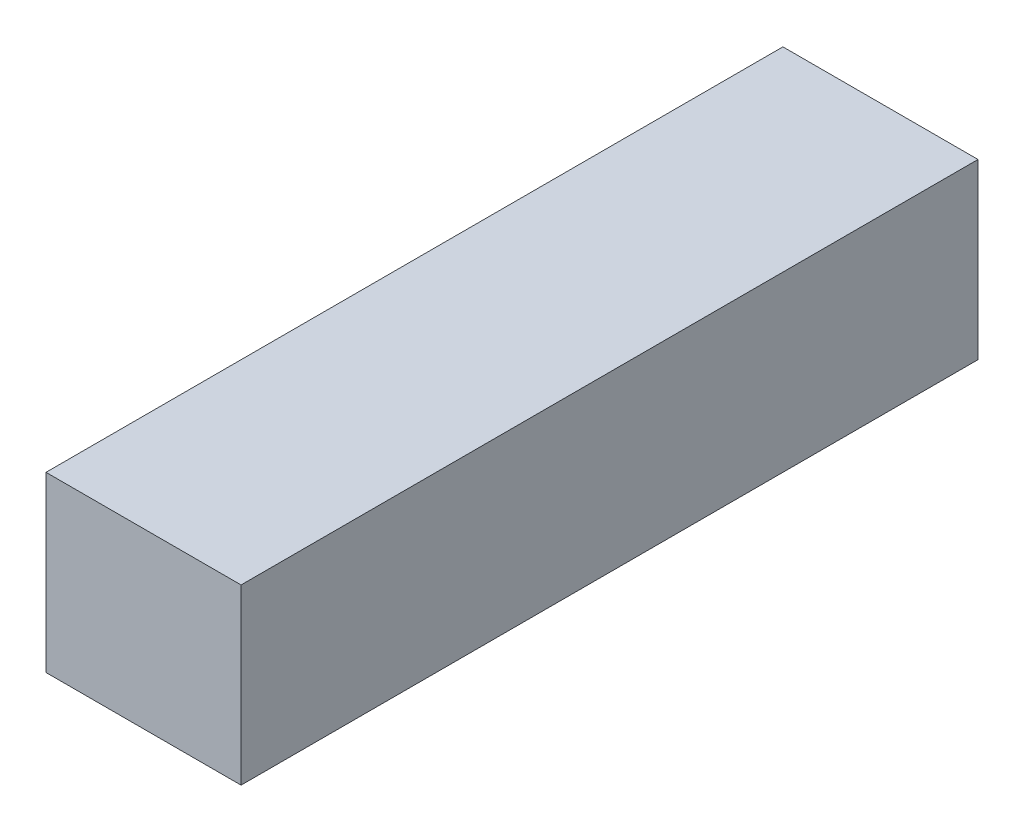
from build123d import *

# Parameters (mm, degrees)
ESQUISSE1_W        = 45
ESQUISSE1_H        = 40
BOSS_EXTRU_1_DEPTH = 170


with BuildPart() as part:
    # Esquisse1 → Boss.-Extru.1 (new body)
    with BuildSketch(Plane.XY):
        with Locations((-13.615564763, 2.403846154)):
            Rectangle(ESQUISSE1_W, ESQUISSE1_H)
    extrude(amount=BOSS_EXTRU_1_DEPTH)


solid = part.part
